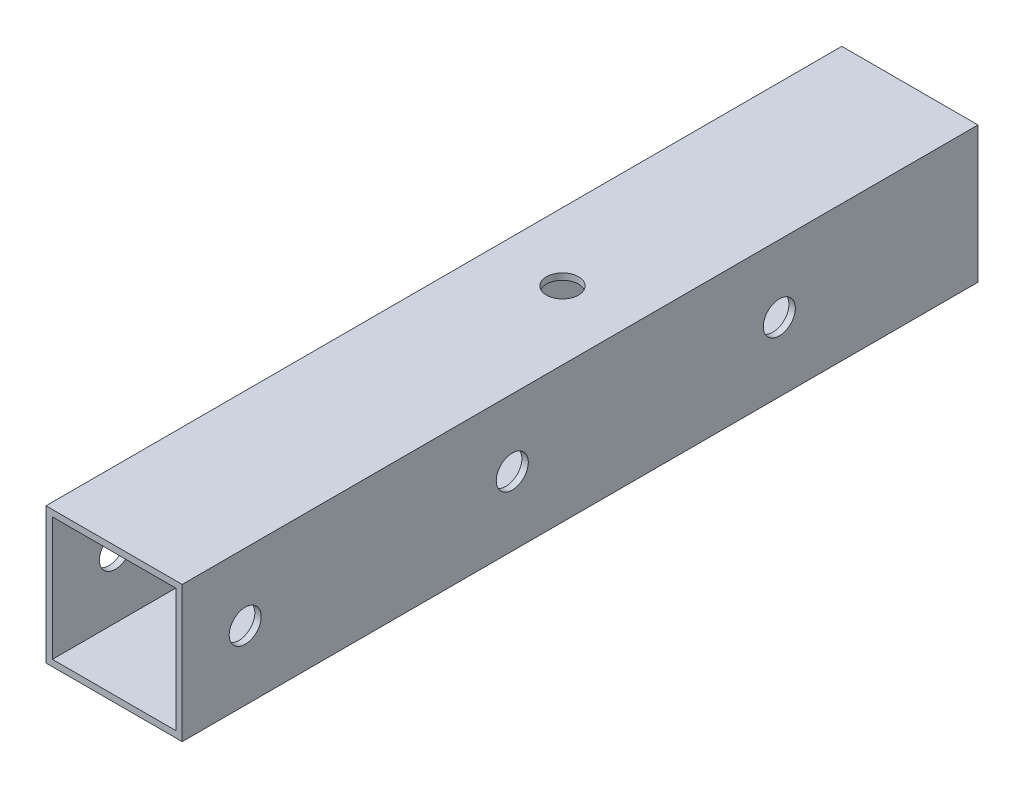
from build123d import *

# Parameters (mm, degrees)
SKETCH1_W                = 25.5
SKETCH1_H                = 25.5
SKETCH1_W_2              = 23.1
SKETCH1_H_2              = 23.1
BOSS_EXTRUDE1_DEPTH      = 149
F_6_0_6_DIAMETER_HOLE5_D = 6
F_6_0_6_DIAMETER_HOLE7_D = 6


with BuildPart() as part:
    # Sketch1 → Boss-Extrude1 (new body)
    with BuildSketch(Plane.XY):
        Rectangle(SKETCH1_W, SKETCH1_H)
        Rectangle(SKETCH1_W_2, SKETCH1_H_2, mode=Mode.SUBTRACT)
    extrude(amount=BOSS_EXTRUDE1_DEPTH)

    # Ø6.0 (6) Diameter Hole5 (through all)
    with Locations(Plane(origin=(-0.05, -21.75, 65), x_dir=(0, 0, -1), z_dir=(0, -1, 0))):
        with Locations((0, 0)):
            Hole(F_6_0_6_DIAMETER_HOLE5_D / 2)

    # Ø6.0 (6) Diameter Hole7 (through all)
    with Locations(Plane.ZY.offset(12.75)):
        with Locations((37.2, 0.15), (87.2, 0.15), (137.2, 0.15)):
            Hole(F_6_0_6_DIAMETER_HOLE7_D / 2)


solid = part.part
